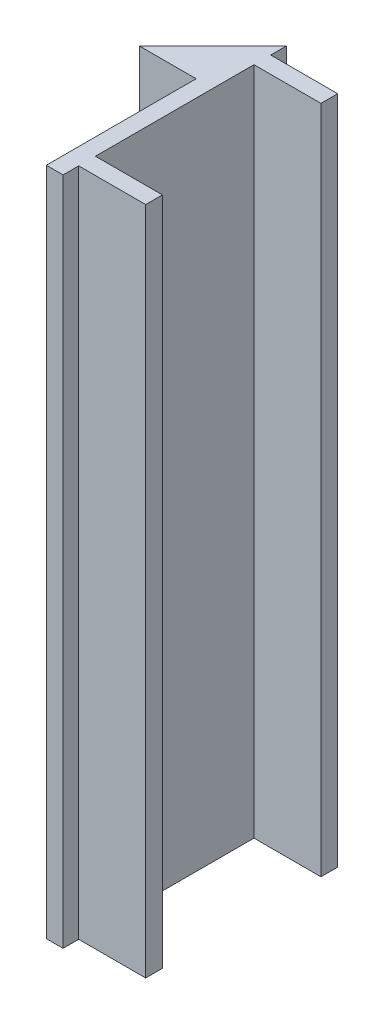
from build123d import *

# Parameters (mm, degrees)
BOSS_EXTRUDE1_DEPTH = 300
SKETCH3_R           = 2.5
CUT_EXTRUDE1_DEPTH  = 51
SKETCH4_R           = 5
CUT_EXTRUDE2_DEPTH  = 19


with BuildPart() as part:
    # Sketch1 → Boss-Extrude1 (new body)
    with BuildSketch(Plane(origin=(0, 0, 0), x_dir=(1, 0, 0), z_dir=(0, 1, 0))):
        Polygon((0, 0), (25.4, 0), (25.4, -50.8), (25.4, -67.1), (32.9, -67.1), (32.9, -60.1), (62.9, -60.1), (62.9, -52.6), (32.9, -52.6), (32.9, 18.4), (62.9, 18.4), (62.9, 25.9), (32.9, 25.9), (32.9, 32.9), align=None)
    extrude(amount=BOSS_EXTRUDE1_DEPTH)

    # Sketch3 → Cut-Extrude1 (cut)
    with BuildSketch(Plane(origin=(-25.9, 0, -25.9), x_dir=(1, 0, 0), z_dir=(0, 0, 1))):
        with Locations((38.6, 275)):
            Circle(SKETCH3_R)
        with Locations((38.6, 200)):
            Circle(SKETCH3_R)
        with Locations((38.6, 100)):
            Circle(SKETCH3_R)
        with Locations((38.6, 25)):
            Circle(SKETCH3_R)
    extrude(amount=CUT_EXTRUDE1_DEPTH, mode=Mode.SUBTRACT)

    # Sketch4 → Cut-Extrude2 (cut)
    with BuildSketch(Plane(origin=(0, 0, -25.9), x_dir=(-1, 0, 0), z_dir=(0, 0, -1))):
        with Locations((-12.7, 275)):
            Circle(SKETCH4_R)
        with Locations((-12.7, 200)):
            Circle(SKETCH4_R)
        with Locations((-12.7, 100)):
            Circle(SKETCH4_R)
        with Locations((-12.7, 25)):
            Circle(SKETCH4_R)
    extrude(amount=-CUT_EXTRUDE2_DEPTH, mode=Mode.SUBTRACT)


solid = part.part
